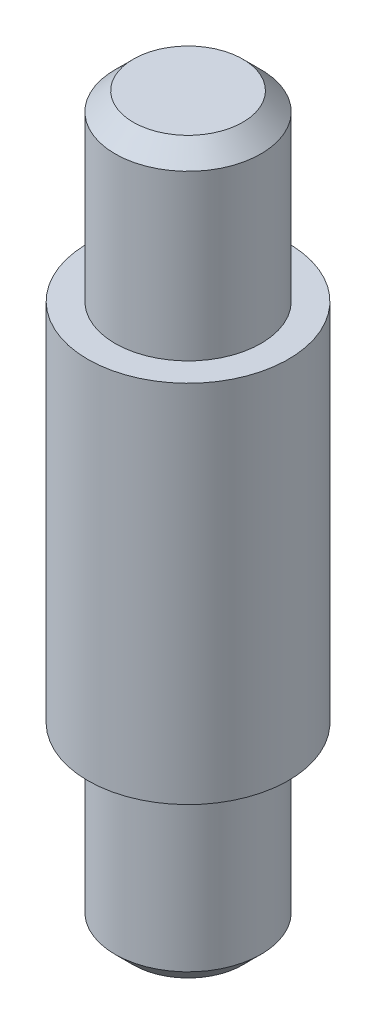
from build123d import *

# Parameters (mm, degrees)
CROQUIS1_R              = 8
SALIENTE_EXTRUIR1_DEPTH = 80
CROQUIS2_R              = 11
SALIENTE_EXTRUIR2_DEPTH = 20
CHAFL_N1_SIZE           = 2
CHAFL_N2_SIZE           = 2


with BuildPart() as part:
    # Croquis1 → Saliente-Extruir1 (new body)
    with BuildSketch(Plane(origin=(0, 0, 0), x_dir=(1, 0, 0), z_dir=(0, 1, 0))):
        Circle(CROQUIS1_R)
    extrude(amount=SALIENTE_EXTRUIR1_DEPTH)

    # Croquis2 → Saliente-Extruir2 (add, symmetric)
    with BuildSketch(Plane(origin=(0, 40, 0), x_dir=(1, 0, 0), z_dir=(0, 1, 0))):
        Circle(CROQUIS2_R)
    extrude(amount=SALIENTE_EXTRUIR2_DEPTH, both=True)

    # Chaflán1
    chafl_n1_edges = [part.edges().sort_by_distance(p)[0] for p in [
        (-8, 80, 0),
    ]]
    chamfer(chafl_n1_edges, length=CHAFL_N1_SIZE)

    # Chaflán2
    chafl_n2_edges = [part.edges().sort_by_distance(p)[0] for p in [
        (-8, 0, 0),
    ]]
    chamfer(chafl_n2_edges, length=CHAFL_N2_SIZE)


solid = part.part
